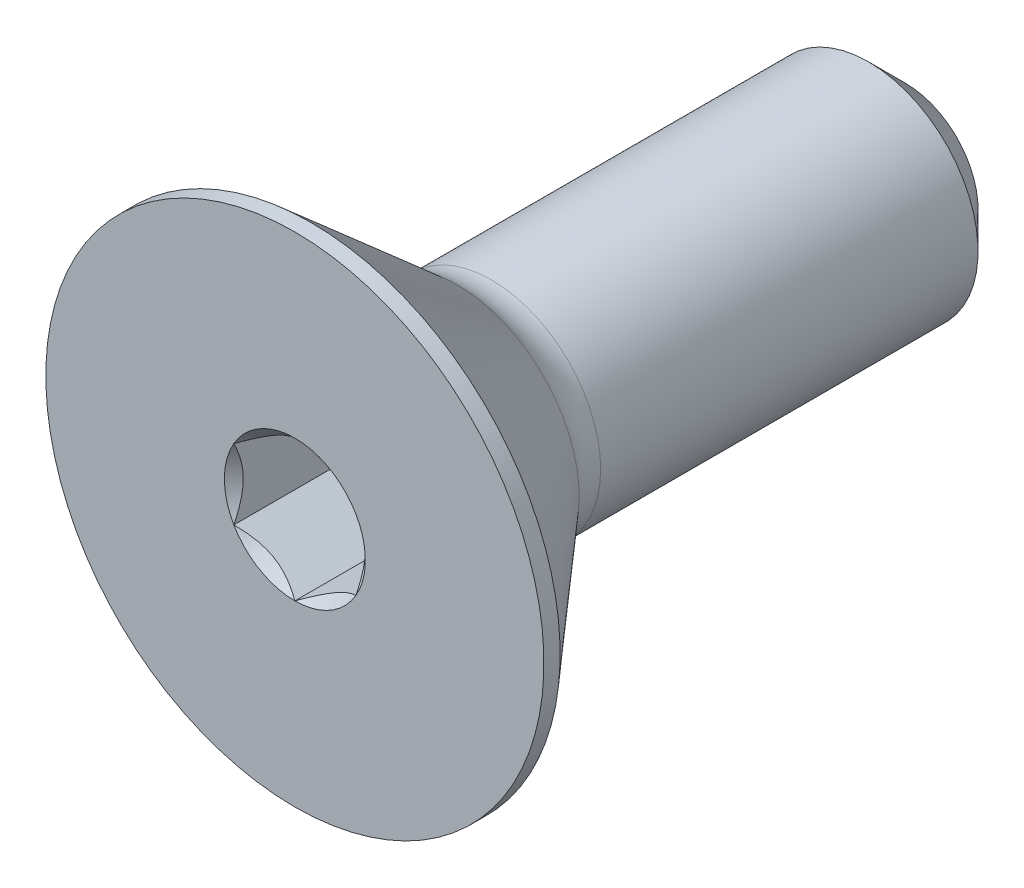
from build123d import *

# Parameters (mm, degrees)
SKETCH1_W          = 7.9375
SKETCH1_H          = 1.4224
CHAMFER1_SIZE      = 0.47625
CUT_EXTRUDE2_DEPTH = 1.47574


with BuildPart() as part:
    # Sketch1 → Revolve1 (revolve)
    with BuildSketch(Plane(origin=(0, 0, 0), x_dir=(0, 0, -1), z_dir=(1, 0, 0))):
        with Locations((3.96875, 0.7112)):
            Rectangle(SKETCH1_W, SKETCH1_H)
    revolve(axis=Axis((0, 0, -7.9375), (0, 0, 1)))

    # Chamfer1
    chamfer1_edges = [part.edges().sort_by_distance(p)[0] for p in [
        (0, -1.4224, -7.9375),
    ]]
    chamfer(chamfer1_edges, length=CHAMFER1_SIZE)


with BuildPart() as body_2:
    # Sketch7 → Revolve2 (revolve)
    with BuildSketch(Plane(origin=(0, 0, 0), x_dir=(0, 0, -1), z_dir=(1, 0, 0)), mode=Mode.PRIVATE) as revolve2_sk:
        with BuildLine():
            Line((0, 3.2385), (0.21082, 3.2385))
            Line((0.21082, 3.2385), (2.1082, 1.589132729))
            ThreePointArc((2.1082, 1.589132729), (2.316098376, 1.465446193), (2.554146942, 1.4224))
            Line((2.554146942, 1.4224), (2.554146942, 0))
            Line((2.554146942, 0), (0, 0))
            Line((0, 0), (0, 3.2385))
        make_face()
    revolve(revolve2_sk.sketch.rotate(Axis((0, 0, 0), (0, 0, -1)), 180), axis=Axis((0, 0, 0), (0, 0, -1)))

    # Boss-Extrude1 cone 1 section (through the dimple's axis) → Boss-Extrude1 (revolve)
    with BuildSketch(Plane(origin=(0, 0, -2.554146942), x_dir=(0, -1, 0), z_dir=(1, 0, 0))):
        Polygon((0, 0), (1.4224, 0), (0, 1.4224), align=None)
    revolve(axis=Axis((0, 0, -2.554146942), (0, 0, -1)))

    # Combine1: union part
    add(part.part)

    # Sketch5 → Cut-Extrude2 (cut)
    with BuildSketch(Plane.XY):
        Polygon((0.79375, -0.458271776), (0.79375, 0.458271776), (0, 0.916543552), (-0.79375, 0.458271776), (-0.79375, -0.458271776), (0, -0.916543552), align=None)
    extrude(amount=-CUT_EXTRUDE2_DEPTH, mode=Mode.SUBTRACT)

    # Cut-Extrude3 cone 1 section (through the dimple's axis) → Cut-Extrude3 (revolve, cut)
    with BuildSketch(Plane(origin=(0, 0, 0), x_dir=(0, -1, 0), z_dir=(1, 0, 0))):
        Polygon((0, 0), (0.916543552, 0), (0, 0.916543552), align=None)
    revolve(axis=Axis((0, 0, 0), (0, 0, -1)), mode=Mode.SUBTRACT)


solid = body_2.part
